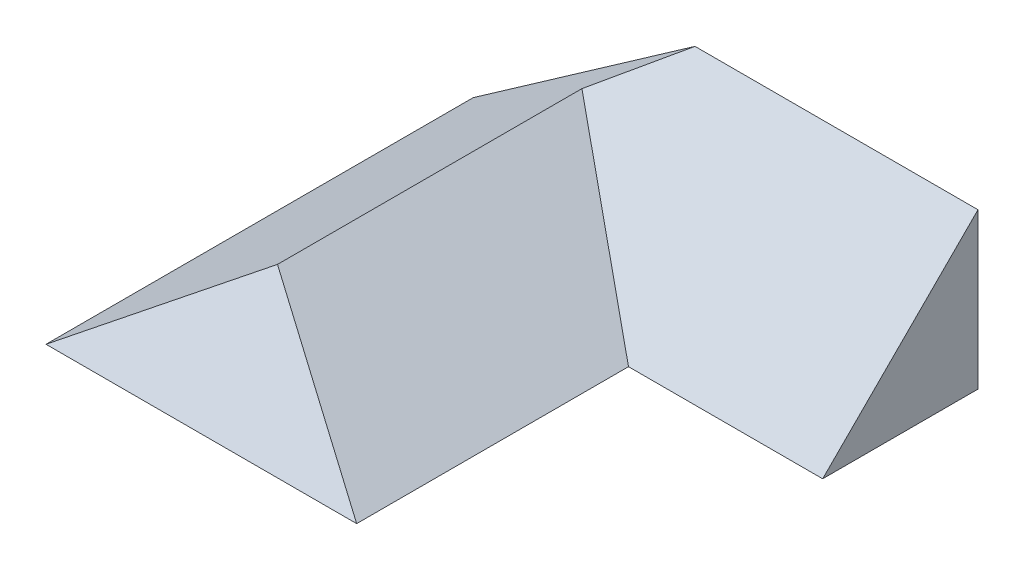
from build123d import *

# Parameters (mm, degrees)
EXTRUDE1_DEPTH     = 110
CUT_EXTRUDE1_DEPTH = 81
EXTRUDE2_DEPTH     = 90
SKETCH4_W          = 71.56019469
SKETCH4_H          = 34.192707118
CUT_EXTRUDE2_DEPTH = 10


with BuildPart() as part:
    # Sketch1 → Extrude1 (new body)
    with BuildSketch(Plane.XY):
        Polygon((0, 0), (80, 0), (40, 28.008301528), align=None)
    extrude(amount=-EXTRUDE1_DEPTH)

    # Sketch2 → Cut-Extrude1 (cut, through all)
    with BuildSketch(Plane(origin=(0, 0, 0), x_dir=(0, 0, -1), z_dir=(1, 0, 0))):
        Polygon((0, 0), (19.611623863, 28.008301528), (0, 28.008301528), align=None)
    extrude(amount=CUT_EXTRUDE1_DEPTH, mode=Mode.SUBTRACT)

    # Sketch3 → Extrude2 (add)
    with BuildSketch(Plane(origin=(130, 0, 0), x_dir=(0, 0, -1), z_dir=(1, 0, 0))):
        Polygon((110, 0), (70, 0), (110, 40), align=None)
    extrude(amount=-EXTRUDE2_DEPTH)

    # Sketch4 → Cut-Extrude2 (cut)
    with BuildSketch(Plane(origin=(0, 0, 0), x_dir=(-0.819152044, -0.573576436, 0), z_dir=(-0.573576436, 0.819152044, 0))):
        with Locations((-35.780097345, -92.903646441)):
            Rectangle(SKETCH4_W, SKETCH4_H)
    extrude(amount=CUT_EXTRUDE2_DEPTH, mode=Mode.SUBTRACT)


solid = part.part
